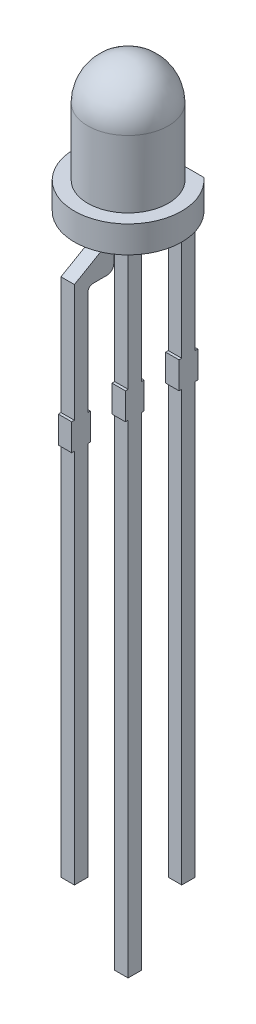
from build123d import *

# Parameters (mm, degrees)
EXTRUDE1_DEPTH     = 1
EXTRUDE2_DEPTH     = 0.25
SKETCH3_W          = 0.026582278
SKETCH3_H          = 0.025316456
CUT_EXTRUDE1_DEPTH = 0.01


with BuildPart() as part:
    # Sketch1 → Extrude1 (new body)
    with BuildSketch(Plane(origin=(0, 0, 0), x_dir=(1, 0, 0), z_dir=(0, 1, 0))):
        with BuildLine():
            Line((1.322875656, 1.5), (-1.322875656, 1.5))
            ThreePointArc((-1.322875656, 1.5), (-0.822875656, -1.822875656), (2, 0))
            ThreePointArc((2, 0), (1.822875656, 0.822875656), (1.322875656, 1.5))
        make_face()
    extrude(amount=EXTRUDE1_DEPTH)

    # Sketch2 → Revolve1 (revolve)
    with BuildSketch(Plane(origin=(0, 0, 0), x_dir=(0, 0, -1), z_dir=(1, 0, 0)), mode=Mode.PRIVATE) as revolve1_sk:
        with BuildLine():
            ThreePointArc((0, 5), (1.060660172, 4.560660172), (1.5, 3.5))
            Line((1.5, 3.5), (1.5, 1))
            Line((1.5, 1), (0, 1))
            Line((0, 1), (0, 5))
        make_face()
    revolve(revolve1_sk.sketch.rotate(Axis((0, 1, 0), (0, 1, 0)), 180), axis=Axis((0, 1, 0), (0, 1, 0)))  # turned: the seam where the file's is

    # Sketch2_3 → Extrude2 (add, symmetric)
    with BuildSketch(Plane(origin=(0, 0, 0), x_dir=(0, 0, -1), z_dir=(1, 0, 0))):
        with BuildLine():
            Line((1.177495486, -0.5), (1.177495486, 0))
            Line((1.177495486, 0), (0.677495486, 0))
            Line((0.677495486, 0), (0.677495486, -1.03))
            ThreePointArc((0.677495486, -1.03), (0.794652774, -1.312842712), (1.077495486, -1.43))
            Line((1.077495486, -1.43), (1.65, -1.43))
            ThreePointArc((1.65, -1.43), (1.720710678, -1.459289322), (1.75, -1.53))
            Line((1.75, -1.53), (1.75, -5.5))
            Line((1.75, -5.5), (1.65, -5.5))
            Line((1.65, -5.5), (1.65, -6.5))
            Line((1.65, -6.5), (1.75, -6.5))
            Line((1.75, -6.5), (1.75, -22.5))
            Line((1.75, -22.5), (2.25, -22.5))
            Line((2.25, -22.5), (2.25, -6.5))
            Line((2.25, -6.5), (2.35, -6.5))
            Line((2.35, -6.5), (2.35, -5.5))
            Line((2.35, -5.5), (2.25, -5.5))
            Line((2.25, -5.5), (2.25, -1.11921077))
            Line((2.25, -1.11921077), (1.177495486, -0.5))
        make_face()
        with BuildLine():
            Line((-0.677495486, 0), (-1.177495486, 0))
            Line((-1.177495486, 0), (-1.177495486, -0.5))
            Line((-1.177495486, -0.5), (-2.25, -1.11921077))
            Line((-2.25, -1.11921077), (-2.25, -5.5))
            Line((-2.25, -5.5), (-2.35, -5.5))
            Line((-2.35, -5.5), (-2.35, -6.5))
            Line((-2.35, -6.5), (-2.25, -6.5))
            Line((-2.25, -6.5), (-2.25, -20.5))
            Line((-2.25, -20.5), (-1.75, -20.5))
            Line((-1.75, -20.5), (-1.75, -6.5))
            Line((-1.75, -6.5), (-1.65, -6.5))
            Line((-1.65, -6.5), (-1.65, -5.5))
            Line((-1.65, -5.5), (-1.75, -5.5))
            Line((-1.75, -5.5), (-1.75, -1.63))
            ThreePointArc((-1.75, -1.63), (-1.691421356, -1.488578644), (-1.55, -1.43))
            Line((-1.55, -1.43), (-1.03296796, -1.43))
            ThreePointArc((-1.03296796, -1.43), (-0.856191265, -1.356776695), (-0.78296796, -1.18))
            Line((-0.78296796, -1.18), (-0.78296796, -0.913641717))
            Line((-0.78296796, -0.913641717), (-0.677495486, -0.858841506))
            Line((-0.677495486, -0.858841506), (-0.677495486, 0))
        make_face()
        Polygon((0.25, 0), (-0.25, 0), (-0.25, -5.5), (-0.35, -5.5), (-0.35, -6.5), (-0.25, -6.5), (-0.25, -24.5), (0.25, -24.5), (0.25, -6.5), (0.35, -6.5), (0.35, -5.5), (0.25, -5.5), align=None)
    extrude(amount=EXTRUDE2_DEPTH, both=True)

    # Sketch3 → Cut-Extrude1 (cut)
    with BuildSketch(Plane.XZ):
        Polygon((-0.623396943, 0.759259634), (-0.698080487, 0.782716913), (-0.698080487, 0.807459793), (-0.647744253, 0.823875932), (-0.698080487, 0.83940204), (-0.698080487, 0.865133843), (-0.623396943, 0.888373558), (-0.623396943, 0.863195552), (-0.674880329, 0.85020109), (-0.623396943, 0.833784951), (-0.623396943, 0.812285742), (-0.674880329, 0.795968495), (-0.623396943, 0.78315204), align=None)
        Polygon((-0.623396943, 0.625082419), (-0.698080487, 0.648539698), (-0.698080487, 0.673282577), (-0.647744253, 0.689698717), (-0.698080487, 0.705224824), (-0.698080487, 0.730956628), (-0.623396943, 0.754196343), (-0.623396943, 0.729018337), (-0.674880329, 0.716023875), (-0.623396943, 0.699607736), (-0.623396943, 0.678108527), (-0.674880329, 0.66179128), (-0.623396943, 0.648974824), align=None)
        Polygon((-0.623396943, 0.490905204), (-0.698080487, 0.514362483), (-0.698080487, 0.539105362), (-0.647744253, 0.555521502), (-0.698080487, 0.571047609), (-0.698080487, 0.596779413), (-0.623396943, 0.620019128), (-0.623396943, 0.594841122), (-0.674880329, 0.58184666), (-0.623396943, 0.565430521), (-0.623396943, 0.543931312), (-0.674880329, 0.527614065), (-0.623396943, 0.514797609), align=None)
        with Locations((-0.684789348, 0.463057103)):
            Rectangle(SKETCH3_W, SKETCH3_H)
        with BuildLine():
            add(Edge.make_bspline(
                [(-0.666909601, 0.346601407), (-0.668131735, 0.346637905), (-0.670531598, 0.346709575), (-0.674039286, 0.347319162), (-0.677363589, 0.348313129), (-0.680527735, 0.349685468), (-0.683497223, 0.351478924), (-0.686300115, 0.353662195), (-0.688904659, 0.356251078), (-0.691341034, 0.359197882), (-0.693523145, 0.362494825), (-0.695429179, 0.366092539), (-0.69702385, 0.369972566), (-0.698362915, 0.374120777), (-0.699351348, 0.378567324), (-0.700075336, 0.383284822), (-0.700548654, 0.38827825), (-0.700590622, 0.391701827), (-0.700612133, 0.393456628)],
                knots=[0, 0, 0, 0, 0.907312236, 1.78165839, 2.635367075, 3.479697475, 4.336364812, 5.205276731, 6.11257575, 7.058770404, 8.040786331, 9.044147278, 10.078219212, 11.153049307, 12.278104542, 13.457648573, 14.696882856, 16, 16, 16, 16], degree=3))
            add(Edge.make_bspline(
                [(-0.700612133, 0.393456628), (-0.700588061, 0.395474884), (-0.700541437, 0.399384066), (-0.700112837, 0.405047591), (-0.699466698, 0.410315628), (-0.698500156, 0.415211343), (-0.697299391, 0.419815942), (-0.696008099, 0.42424921), (-0.694543684, 0.428530522), (-0.693443526, 0.431303611), (-0.692898525, 0.432677356)],
                knots=[0, 0, 0, 0, 1.203215828, 2.33052265, 3.384689099, 4.366106119, 5.303329643, 6.221311756, 7.118865988, 8, 8, 8, 8], degree=3))
            Line((-0.692898525, 0.432677356), (-0.668966563, 0.432677356))
            Line((-0.668966563, 0.432677356), (-0.668966563, 0.429829255))
            add(Edge.make_bspline(
                [(-0.668966563, 0.429829255), (-0.670048018, 0.428463941), (-0.672204579, 0.425741328), (-0.674967184, 0.421308095), (-0.677369347, 0.416660449), (-0.679343349, 0.411814978), (-0.680929673, 0.406918134), (-0.682023201, 0.402042756), (-0.68277055, 0.397277169), (-0.682851056, 0.394118599), (-0.682890614, 0.392566596)],
                knots=[0, 0, 0, 0, 1.030622468, 2.055194264, 3.087043286, 4.125157485, 5.149848264, 6.130935704, 7.081611712, 8, 8, 8, 8], degree=3))
            add(Edge.make_bspline(
                [(-0.682890614, 0.392566596), (-0.682889719, 0.392137818), (-0.682887805, 0.391219836), (-0.682758962, 0.389751799), (-0.682665798, 0.3880932), (-0.68245658, 0.386314334), (-0.682237997, 0.384523516), (-0.681857677, 0.382868856), (-0.681495838, 0.381365217), (-0.681127661, 0.380458735), (-0.680952323, 0.38002704)],
                knots=[0, 0, 0, 0, 0.806378557, 1.726393851, 2.771014456, 3.931269413, 5.096090628, 6.161710732, 7.124547685, 8, 8, 8, 8], degree=3))
            add(Edge.make_bspline(
                [(-0.680952323, 0.38002704), (-0.680724499, 0.379547253), (-0.680276777, 0.378604369), (-0.67945917, 0.37730945), (-0.678587868, 0.376126778), (-0.677622449, 0.375065317), (-0.676444541, 0.37421505), (-0.675043685, 0.373586849), (-0.673393384, 0.373243755), (-0.672218374, 0.373204461), (-0.671597101, 0.373183685)],
                knots=[0, 0, 0, 0, 1.024407818, 2.013179384, 2.949802342, 3.859052226, 4.77034807, 5.732977883, 6.801339628, 8, 8, 8, 8], degree=3))
            add(Edge.make_bspline(
                [(-0.671597101, 0.373183685), (-0.671051205, 0.373215127), (-0.669977813, 0.37327695), (-0.668449816, 0.373858742), (-0.667027939, 0.37474164), (-0.665767224, 0.376028663), (-0.664609786, 0.377622739), (-0.663639489, 0.379578476), (-0.662759415, 0.381831455), (-0.662342146, 0.383475914), (-0.662123209, 0.384338748)],
                knots=[0, 0, 0, 0, 0.825212765, 1.622611382, 2.449701629, 3.348069183, 4.336544339, 5.428209675, 6.6506027, 8, 8, 8, 8], degree=3))
            add(Edge.make_bspline(
                [(-0.662123209, 0.384338748), (-0.661675468, 0.386307476), (-0.660758278, 0.390340383), (-0.659611171, 0.396488492), (-0.658345098, 0.40261872), (-0.657135557, 0.406577432), (-0.656545677, 0.408508052)],
                knots=[0, 0, 0, 0, 0.976104583, 1.999535498, 3.024395274, 4, 4, 4, 4], degree=3))
            add(Edge.make_bspline(
                [(-0.656545677, 0.408508052), (-0.656192685, 0.409546568), (-0.655505551, 0.411568136), (-0.654343926, 0.41445968), (-0.653073974, 0.417120793), (-0.651718843, 0.419560903), (-0.650244845, 0.421760225), (-0.648711456, 0.423755415), (-0.647057618, 0.425498941), (-0.645325699, 0.427046625), (-0.643473696, 0.428369939), (-0.64152956, 0.42952469), (-0.639469094, 0.430500325), (-0.637307806, 0.431309209), (-0.635028937, 0.431926281), (-0.632652064, 0.432347537), (-0.630168703, 0.432645926), (-0.62847435, 0.432666737), (-0.627609759, 0.432677356)],
                knots=[0, 0, 0, 0, 1.287286806, 2.505824366, 3.654938963, 4.74627059, 5.778586806, 6.75996495, 7.696030012, 8.595059759, 9.482019644, 10.363222407, 11.245851011, 12.154256429, 13.068444161, 14.012503255, 14.985824751, 16, 16, 16, 16], degree=3))
            add(Edge.make_bspline(
                [(-0.627609759, 0.432677356), (-0.626453615, 0.432640054), (-0.624178343, 0.432566645), (-0.620849298, 0.431965216), (-0.617700562, 0.430938626), (-0.614697099, 0.429552562), (-0.611884012, 0.427723934), (-0.609205465, 0.42553914), (-0.606733874, 0.422915092), (-0.60443354, 0.419937971), (-0.602354141, 0.416650587), (-0.600523585, 0.413111603), (-0.598986933, 0.409342314), (-0.597713039, 0.405356767), (-0.596758369, 0.401138298), (-0.596039437, 0.396701066), (-0.595626255, 0.392027277), (-0.595575005, 0.388835855), (-0.595548842, 0.387206628)],
                knots=[0, 0, 0, 0, 0.894990994, 1.761326291, 2.609044902, 3.454222546, 4.315366365, 5.200560057, 6.125081389, 7.100429509, 8.110379559, 9.133447974, 10.182136699, 11.259192205, 12.370181258, 13.528580438, 14.738335141, 16, 16, 16, 16], degree=3))
            add(Edge.make_bspline(
                [(-0.595548842, 0.387206628), (-0.595571033, 0.385537941), (-0.595615379, 0.382203396), (-0.595993356, 0.377221954), (-0.596548584, 0.372261452), (-0.59739029, 0.367397622), (-0.598366707, 0.362707067), (-0.599462503, 0.358293831), (-0.600700467, 0.35421437), (-0.601654812, 0.351640706), (-0.602115297, 0.350398875)],
                knots=[0, 0, 0, 0, 1.065403572, 2.129000689, 3.188532477, 4.251604565, 5.279552602, 6.247508681, 7.154397237, 8, 8, 8, 8], degree=3))
            Line((-0.602115297, 0.350398875), (-0.624662766, 0.350398875))
            Line((-0.624662766, 0.350398875), (-0.624662766, 0.353227198))
            add(Edge.make_bspline(
                [(-0.624662766, 0.353227198), (-0.623862419, 0.354300102), (-0.622225689, 0.356494221), (-0.620142017, 0.360153858), (-0.618184151, 0.364112093), (-0.616499993, 0.368390924), (-0.615040511, 0.372849951), (-0.614021345, 0.37743291), (-0.613379536, 0.382059074), (-0.613306761, 0.385160785), (-0.613270361, 0.386712166)],
                knots=[0, 0, 0, 0, 0.892283326, 1.824742884, 2.804416662, 3.836872171, 4.8899239, 5.931447339, 6.965372909, 8, 8, 8, 8], degree=3))
            add(Edge.make_bspline(
                [(-0.613270361, 0.386712166), (-0.613291813, 0.387807834), (-0.613334715, 0.38999905), (-0.613725399, 0.393267259), (-0.614356293, 0.39650932), (-0.615175575, 0.398549843), (-0.615584443, 0.399568179)],
                knots=[0, 0, 0, 0, 0.999146175, 1.998183711, 3.000980573, 4, 4, 4, 4], degree=3))
            add(Edge.make_bspline(
                [(-0.615584443, 0.399568179), (-0.61578591, 0.400001682), (-0.616188709, 0.400868399), (-0.616961273, 0.402075044), (-0.617890084, 0.403179713), (-0.618942076, 0.40417179), (-0.62009845, 0.405040188), (-0.621373276, 0.405655539), (-0.62273619, 0.406031412), (-0.623671421, 0.406073571), (-0.624148525, 0.406095077)],
                knots=[0, 0, 0, 0, 1.00524851, 2.009826503, 3.004679593, 4.035271301, 5.048246368, 6.034938417, 6.997532266, 8, 8, 8, 8], degree=3))
            add(Edge.make_bspline(
                [(-0.624148525, 0.406095077), (-0.624786691, 0.406060639), (-0.626006166, 0.405994831), (-0.627721962, 0.405388247), (-0.629200396, 0.404403413), (-0.630195316, 0.403242809), (-0.630892754, 0.402125679), (-0.631403265, 0.401090019), (-0.631886624, 0.399880792), (-0.632384092, 0.398509545), (-0.632875279, 0.396973218), (-0.633350826, 0.395264661), (-0.633800122, 0.393381944), (-0.634086313, 0.392066069), (-0.634235551, 0.391379888)],
                knots=[0, 0, 0, 0, 1.173816843, 2.243057204, 3.312297565, 4.415174738, 5.03266065, 5.73970059, 6.541434878, 7.433956553, 8.430083051, 9.515931566, 10.70464786, 12, 12, 12, 12], degree=3))
            add(Edge.make_bspline(
                [(-0.634235551, 0.391379888), (-0.634611612, 0.389547098), (-0.63535049, 0.385946072), (-0.636453978, 0.380544889), (-0.637728947, 0.375042115), (-0.63887775, 0.371376789), (-0.639476848, 0.369465331)],
                knots=[0, 0, 0, 0, 0.995744513, 1.956417928, 2.934277412, 4, 4, 4, 4], degree=3))
            add(Edge.make_bspline(
                [(-0.639476848, 0.369465331), (-0.639796092, 0.368518776), (-0.640420585, 0.366667163), (-0.641506867, 0.364026533), (-0.64268085, 0.361579474), (-0.643922382, 0.359312441), (-0.645266348, 0.357238471), (-0.646688994, 0.355343789), (-0.648215903, 0.353659971), (-0.649829131, 0.352162405), (-0.651539232, 0.350843246), (-0.653378304, 0.349710947), (-0.655327106, 0.348738719), (-0.657413306, 0.347969114), (-0.659607893, 0.347351094), (-0.661939261, 0.346927997), (-0.664383638, 0.346634013), (-0.666058215, 0.346612397), (-0.666909601, 0.346601407)],
                knots=[0, 0, 0, 0, 1.237467875, 2.420686895, 3.535046182, 4.599015201, 5.620884487, 6.594603852, 7.531477383, 8.433220087, 9.318759595, 10.202828513, 11.105163009, 12.01247538, 12.953896178, 13.926381251, 14.945733412, 16, 16, 16, 16], degree=3))
        make_face()
        with BuildLine():
            Line((-0.698080487, 0.254196343), (-0.698080487, 0.278246976))
            Line((-0.698080487, 0.278246976), (-0.690248209, 0.278246976))
            add(Edge.make_bspline(
                [(-0.690248209, 0.278246976), (-0.691056767, 0.279340285), (-0.692615656, 0.281448168), (-0.694695873, 0.284621193), (-0.696471139, 0.287647284), (-0.69803036, 0.290560774), (-0.699205746, 0.293582978), (-0.700033812, 0.296814492), (-0.700533584, 0.300317317), (-0.700585368, 0.302744211), (-0.700612133, 0.303998558)],
                knots=[0, 0, 0, 0, 1.150872466, 2.218865267, 3.209461834, 4.120482262, 5.012764827, 5.946708227, 6.938749913, 8, 8, 8, 8], degree=3))
            add(Edge.make_bspline(
                [(-0.700612133, 0.303998558), (-0.700589414, 0.30501491), (-0.700545174, 0.306994041), (-0.700200296, 0.309871281), (-0.699662644, 0.312578909), (-0.698855053, 0.315093949), (-0.69788925, 0.317457938), (-0.696609292, 0.319595488), (-0.695179118, 0.321599089), (-0.693472072, 0.323380762), (-0.691574339, 0.324996383), (-0.689441879, 0.326378933), (-0.687108954, 0.327556644), (-0.6845571, 0.328497742), (-0.681798796, 0.329252832), (-0.678819549, 0.329776764), (-0.675632421, 0.330097356), (-0.673437291, 0.330129296), (-0.672309127, 0.33014571)],
                knots=[0, 0, 0, 0, 1.109008058, 2.159558935, 3.158726032, 4.116861086, 5.039058877, 5.938775559, 6.82970133, 7.720510853, 8.624361809, 9.544451588, 10.487360536, 11.471068125, 12.508000841, 13.604731202, 14.768976642, 16, 16, 16, 16], degree=3))
            Line((-0.672309127, 0.33014571), (-0.623396943, 0.33014571))
            Line((-0.623396943, 0.33014571), (-0.623396943, 0.306095077))
            Line((-0.623396943, 0.306095077), (-0.660976057, 0.306095077))
            add(Edge.make_bspline(
                [(-0.660976057, 0.306095077), (-0.661892528, 0.306093442), (-0.663646744, 0.306090311), (-0.66615255, 0.306007973), (-0.668420723, 0.305887072), (-0.670462751, 0.305748367), (-0.672309502, 0.305495351), (-0.673975663, 0.305117642), (-0.675495265, 0.304646816), (-0.676401966, 0.304182497), (-0.676838399, 0.303959002)],
                knots=[0, 0, 0, 0, 1.361401701, 2.605856924, 3.723918663, 4.735739235, 5.645738665, 6.489217889, 7.27279937, 8, 8, 8, 8], degree=3))
            add(Edge.make_bspline(
                [(-0.676838399, 0.303959002), (-0.677237114, 0.303728995), (-0.678020953, 0.303276821), (-0.679027131, 0.302356532), (-0.679871399, 0.301277789), (-0.680527427, 0.300000185), (-0.681026376, 0.298513637), (-0.681366613, 0.296785706), (-0.681582114, 0.294800345), (-0.681610023, 0.293391327), (-0.681624791, 0.29264571)],
                knots=[0, 0, 0, 0, 0.849138082, 1.669332372, 2.503455908, 3.370611167, 4.311442699, 5.394692208, 6.621337967, 8, 8, 8, 8], degree=3))
            add(Edge.make_bspline(
                [(-0.681624791, 0.29264571), (-0.681607434, 0.292104426), (-0.681571747, 0.290991509), (-0.681339301, 0.289280196), (-0.680982626, 0.287483619), (-0.680322771, 0.284969037), (-0.679136591, 0.281802409), (-0.677782184, 0.279443108), (-0.677095519, 0.278246976)],
                knots=[0, 0, 0, 0, 0.638127216, 1.312033637, 2.033062677, 2.79661882, 4.375931797, 6, 6, 6, 6], degree=3))
            Line((-0.677095519, 0.278246976), (-0.623396943, 0.278246976))
            Line((-0.623396943, 0.278246976), (-0.623396943, 0.254196343))
            Line((-0.623396943, 0.254196343), (-0.698080487, 0.254196343))
        make_face()
        with BuildLine():
            Line((-0.698080487, 0.156727989), (-0.698080487, 0.180778622))
            Line((-0.698080487, 0.180778622), (-0.660501373, 0.180778622))
            add(Edge.make_bspline(
                [(-0.660501373, 0.180778622), (-0.658971331, 0.180803136), (-0.655920305, 0.18085202), (-0.652157895, 0.181134144), (-0.64931557, 0.181512666), (-0.647477689, 0.181882321), (-0.64592955, 0.182314021), (-0.645043791, 0.182726301), (-0.644639032, 0.182914698)],
                knots=[0, 0, 0, 0, 1.709124929, 3.408128882, 4.211124727, 4.91016634, 5.501986363, 6, 6, 6, 6], degree=3))
            add(Edge.make_bspline(
                [(-0.644639032, 0.182914698), (-0.644240978, 0.18315916), (-0.643460539, 0.183638464), (-0.642447525, 0.184575788), (-0.641618684, 0.185669674), (-0.640937134, 0.186940444), (-0.640466553, 0.188431641), (-0.640073323, 0.190148381), (-0.639906414, 0.192134999), (-0.639871254, 0.193542269), (-0.639852639, 0.194287324)],
                knots=[0, 0, 0, 0, 0.86006424, 1.686277094, 2.52783008, 3.38194165, 4.331801563, 5.402842185, 6.624978739, 8, 8, 8, 8], degree=3))
            add(Edge.make_bspline(
                [(-0.639852639, 0.194287324), (-0.639909377, 0.195419146), (-0.64002523, 0.197730241), (-0.640736737, 0.200592434), (-0.641555697, 0.202923038), (-0.642314527, 0.204775562), (-0.643285969, 0.206684193), (-0.644007791, 0.207963605), (-0.644381911, 0.208626723)],
                knots=[0, 0, 0, 0, 1.338371478, 2.732853438, 3.468019217, 4.261884641, 5.099136535, 6, 6, 6, 6], degree=3))
            Line((-0.644381911, 0.208626723), (-0.698080487, 0.208626723))
            Line((-0.698080487, 0.208626723), (-0.698080487, 0.232677356))
            Line((-0.698080487, 0.232677356), (-0.623396943, 0.232677356))
            Line((-0.623396943, 0.232677356), (-0.623396943, 0.208626723))
            Line((-0.623396943, 0.208626723), (-0.631229221, 0.208626723))
            add(Edge.make_bspline(
                [(-0.631229221, 0.208626723), (-0.63042307, 0.207569316), (-0.628853848, 0.205511012), (-0.626813427, 0.202331774), (-0.625014658, 0.199247876), (-0.623501841, 0.196194866), (-0.622295067, 0.193079911), (-0.621484078, 0.189817153), (-0.620940275, 0.186400747), (-0.620890581, 0.184064032), (-0.620865297, 0.182875141)],
                knots=[0, 0, 0, 0, 1.126119141, 2.192057864, 3.198061997, 4.149848529, 5.076251285, 6.021887753, 6.99356175, 8, 8, 8, 8], degree=3))
            add(Edge.make_bspline(
                [(-0.620865297, 0.182875141), (-0.620890686, 0.181878869), (-0.62094025, 0.17993397), (-0.62124996, 0.17709921), (-0.621800624, 0.174427789), (-0.622598454, 0.171935515), (-0.623584066, 0.169592895), (-0.624815581, 0.167430951), (-0.626274004, 0.16543888), (-0.627935006, 0.163610479), (-0.629824733, 0.161979661), (-0.631941997, 0.160562625), (-0.634285094, 0.159382643), (-0.636845403, 0.158411931), (-0.639610512, 0.157637508), (-0.642606477, 0.157122377), (-0.645810656, 0.156768593), (-0.648026699, 0.156741794), (-0.649168304, 0.156727989)],
                knots=[0, 0, 0, 0, 1.08848837, 2.124922927, 3.110950502, 4.063144162, 4.979605775, 5.882838355, 6.774625441, 7.671951181, 8.57587277, 9.494821853, 10.448322275, 11.435533005, 12.482327682, 13.580118324, 14.753386918, 16, 16, 16, 16], degree=3))
            Line((-0.649168304, 0.156727989), (-0.698080487, 0.156727989))
        make_face()
        Polygon((-0.698080487, 0.06179128), (-0.698080487, 0.133943179), (-0.598080487, 0.133943179), (-0.598080487, 0.108626723), (-0.679093146, 0.108626723), (-0.679093146, 0.06179128), align=None)
        Polygon((-0.698080487, -0.025550492), (-0.698080487, 0.046601407), (-0.598080487, 0.046601407), (-0.598080487, -0.025550492), (-0.617067829, -0.025550492), (-0.617067829, 0.021284951), (-0.634789348, 0.021284951), (-0.634789348, -0.021753024), (-0.65377669, -0.021753024), (-0.65377669, 0.021284951), (-0.679093146, 0.021284951), (-0.679093146, -0.025550492), align=None)
        with BuildLine():
            add(Edge.make_bspline(
                [(-0.64817938, -0.142006188), (-0.649327069, -0.141986873), (-0.651599955, -0.141948621), (-0.654964761, -0.14165343), (-0.658230437, -0.141127404), (-0.661414685, -0.140448223), (-0.664493613, -0.139525717), (-0.66750119, -0.138444003), (-0.670406684, -0.137134357), (-0.673208118, -0.135629505), (-0.675880221, -0.133980033), (-0.67840043, -0.132205284), (-0.680783648, -0.130359504), (-0.682978541, -0.128370192), (-0.685020561, -0.12629101), (-0.686911375, -0.124115482), (-0.688614806, -0.121810417), (-0.68963769, -0.120203255), (-0.690149316, -0.119399385)],
                knots=[0, 0, 0, 0, 1.105570398, 2.18947457, 3.250358341, 4.290584537, 5.323553275, 6.344225964, 7.367641686, 8.3905646, 9.405808457, 10.390761353, 11.358902336, 12.307789878, 13.241960776, 14.165076779, 15.082208636, 16, 16, 16, 16], degree=3))
            add(Edge.make_bspline(
                [(-0.690149316, -0.119399385), (-0.690861456, -0.118160156), (-0.692289368, -0.115675377), (-0.693957959, -0.111691542), (-0.695362075, -0.10756606), (-0.696416499, -0.103215673), (-0.697143543, -0.098568664), (-0.69770435, -0.093567255), (-0.69800611, -0.088159665), (-0.69805513, -0.08442477), (-0.698080487, -0.082492739)],
                knots=[0, 0, 0, 0, 0.896288622, 1.797150563, 2.705281913, 3.629615989, 4.602417572, 5.655716007, 6.787320449, 8, 8, 8, 8], degree=3))
            Line((-0.698080487, -0.082492739), (-0.698080487, -0.047069479))
            Line((-0.698080487, -0.047069479), (-0.598080487, -0.047069479))
            Line((-0.598080487, -0.047069479), (-0.598080487, -0.083501442))
            add(Edge.make_bspline(
                [(-0.598080487, -0.083501442), (-0.598097098, -0.085480173), (-0.598129139, -0.089296902), (-0.598546729, -0.094813741), (-0.599143554, -0.099918949), (-0.600068424, -0.104604297), (-0.60118377, -0.108904301), (-0.602542898, -0.112829777), (-0.604041605, -0.116441551), (-0.605315299, -0.118620393), (-0.605932544, -0.119676283)],
                knots=[0, 0, 0, 0, 1.267175336, 2.444223962, 3.542125549, 4.557526608, 5.500936977, 6.385043188, 7.217374394, 8, 8, 8, 8], degree=3))
            add(Edge.make_bspline(
                [(-0.605932544, -0.119676283), (-0.606469085, -0.120527237), (-0.607535998, -0.122219361), (-0.609317851, -0.124620576), (-0.611273928, -0.126850003), (-0.613325746, -0.128978506), (-0.615528633, -0.130958324), (-0.61786734, -0.132801523), (-0.620345434, -0.13450534), (-0.622954904, -0.136063304), (-0.625684955, -0.137484119), (-0.628558014, -0.138673425), (-0.631536544, -0.139722774), (-0.634645507, -0.14052831), (-0.637853343, -0.141226224), (-0.641194687, -0.141660959), (-0.644647175, -0.14194757), (-0.646992065, -0.141986484), (-0.64817938, -0.142006188)],
                knots=[0, 0, 0, 0, 0.964065863, 1.917049184, 2.86229036, 3.805247319, 4.749389377, 5.698846072, 6.657678277, 7.629829384, 8.610569287, 9.604676042, 10.607940105, 11.6349849, 12.681042988, 13.752616828, 14.862056989, 16, 16, 16, 16], degree=3))
        make_face()
        with BuildLine():
            add(Edge.make_bspline(
                [(-0.648021152, -0.11542391), (-0.647216392, -0.115413669), (-0.645637808, -0.115393582), (-0.643322293, -0.115202014), (-0.641092643, -0.114942958), (-0.638957951, -0.114511904), (-0.636898381, -0.114012257), (-0.634940886, -0.113370108), (-0.633061313, -0.112645711), (-0.631283825, -0.111764073), (-0.629575442, -0.110790436), (-0.627989927, -0.109642943), (-0.626477041, -0.108394605), (-0.625049056, -0.107016318), (-0.62374316, -0.105473378), (-0.622513084, -0.103813276), (-0.621384758, -0.102012918), (-0.620724708, -0.10073993), (-0.620390614, -0.100095587)],
                knots=[0, 0, 0, 0, 1.152093354, 2.259898929, 3.325467225, 4.364140538, 5.376172865, 6.358396836, 7.312077728, 8.257828931, 9.196960457, 10.124297759, 11.056236784, 12.004246951, 12.961658638, 13.947279359, 14.960983522, 16, 16, 16, 16], degree=3))
            add(Edge.make_bspline(
                [(-0.620390614, -0.100095587), (-0.620083902, -0.099420689), (-0.619475977, -0.098082995), (-0.618744785, -0.096012172), (-0.618171949, -0.093922789), (-0.617741091, -0.091721189), (-0.61741916, -0.08925143), (-0.617221902, -0.086325848), (-0.617079732, -0.082869939), (-0.617071981, -0.080383224), (-0.617067829, -0.079051283)],
                knots=[0, 0, 0, 0, 0.826967603, 1.639107464, 2.447640171, 3.242670507, 4.14065217, 5.225198036, 6.513753944, 8, 8, 8, 8], degree=3))
            Line((-0.617067829, -0.079051283), (-0.617067829, -0.072385935))
            Line((-0.617067829, -0.072385935), (-0.679093146, -0.072385935))
            Line((-0.679093146, -0.072385935), (-0.679093146, -0.079051283))
            add(Edge.make_bspline(
                [(-0.679093146, -0.079051283), (-0.679088396, -0.07980949), (-0.679079226, -0.081273256), (-0.679036164, -0.083389499), (-0.678989277, -0.085355295), (-0.678872814, -0.087160166), (-0.678800168, -0.088818851), (-0.678621789, -0.090305632), (-0.67847961, -0.091648122), (-0.678211887, -0.093215718), (-0.677795704, -0.095068884), (-0.677117525, -0.097230144), (-0.676267129, -0.099370679), (-0.675582162, -0.100759252), (-0.675236342, -0.101460302)],
                knots=[0, 0, 0, 0, 1.186793418, 2.291178421, 3.313283093, 4.264083014, 5.122158624, 5.910777728, 6.607099052, 7.234812932, 8.398911528, 9.577194775, 10.776795607, 12, 12, 12, 12], degree=3))
            add(Edge.make_bspline(
                [(-0.675236342, -0.101460302), (-0.674894826, -0.102045418), (-0.674221311, -0.103199344), (-0.673087237, -0.104822849), (-0.671879513, -0.106330566), (-0.670591061, -0.107726578), (-0.66920282, -0.108989878), (-0.667736278, -0.110141897), (-0.6661883, -0.111172346), (-0.663994782, -0.112407735), (-0.660963846, -0.113630981), (-0.656996459, -0.114670523), (-0.652636696, -0.115307395), (-0.649599078, -0.115384077), (-0.648021152, -0.11542391)],
                knots=[0, 0, 0, 0, 0.755160452, 1.489275589, 2.205657296, 2.907868421, 3.605098304, 4.296256403, 4.985378686, 5.676536785, 7.100390329, 8.614249252, 10.241231541, 12, 12, 12, 12], degree=3))
        make_face(mode=Mode.SUBTRACT)
        with Locations((-0.684789348, -0.173651758)):
            Rectangle(SKETCH3_W, SKETCH3_H)
        with BuildLine():
            add(Edge.make_bspline(
                [(-0.700612133, -0.248295745), (-0.700590322, -0.246705632), (-0.70054751, -0.243584496), (-0.700070593, -0.239013154), (-0.699352898, -0.234647982), (-0.698331991, -0.230501674), (-0.696984495, -0.226587882), (-0.695331559, -0.222924245), (-0.693346375, -0.219517388), (-0.691767166, -0.217458741), (-0.690980013, -0.216432612)],
                knots=[0, 0, 0, 0, 1.123670284, 2.205584497, 3.245308791, 4.249063313, 5.220352711, 6.167273909, 7.086481357, 8, 8, 8, 8], degree=3))
            add(Edge.make_bspline(
                [(-0.690980013, -0.216432612), (-0.690125238, -0.215480865), (-0.688418996, -0.21358105), (-0.685447569, -0.211115117), (-0.682164525, -0.208992032), (-0.678562302, -0.207206479), (-0.674645573, -0.205775555), (-0.670400911, -0.204752422), (-0.665840131, -0.204133176), (-0.662692197, -0.204066011), (-0.661074949, -0.204031505)],
                knots=[0, 0, 0, 0, 0.916457077, 1.82937027, 2.759194969, 3.714948755, 4.706655623, 5.743329475, 6.840637961, 8, 8, 8, 8], degree=3))
            add(Edge.make_bspline(
                [(-0.661074949, -0.204031505), (-0.659371722, -0.204070265), (-0.656070642, -0.204145388), (-0.651298455, -0.204809148), (-0.646880774, -0.20587876), (-0.642828866, -0.207416318), (-0.639135674, -0.20934676), (-0.635763839, -0.211611253), (-0.632720915, -0.214231779), (-0.630975476, -0.216238917), (-0.630101848, -0.21724353)],
                knots=[0, 0, 0, 0, 1.171797512, 2.271099083, 3.308930235, 4.294129479, 5.24602549, 6.17106565, 7.084581485, 8, 8, 8, 8], degree=3))
            add(Edge.make_bspline(
                [(-0.630101848, -0.21724353), (-0.629333262, -0.2182694), (-0.627786806, -0.220333532), (-0.625886106, -0.223737037), (-0.62429132, -0.227360252), (-0.623043676, -0.231189823), (-0.62208977, -0.235162632), (-0.621365927, -0.239222291), (-0.620945368, -0.243368544), (-0.620892116, -0.246158744), (-0.620865297, -0.247563942)],
                knots=[0, 0, 0, 0, 0.952130878, 1.915761808, 2.890227217, 3.891541892, 4.905612075, 5.925811839, 6.955400088, 8, 8, 8, 8], degree=3))
            add(Edge.make_bspline(
                [(-0.620865297, -0.247563942), (-0.6208823, -0.24881066), (-0.620915732, -0.251262132), (-0.621237841, -0.254863178), (-0.62177096, -0.25831772), (-0.622509563, -0.261622652), (-0.623401166, -0.264796598), (-0.624440308, -0.267846775), (-0.625573575, -0.270806585), (-0.62645811, -0.272707154), (-0.626897734, -0.273651758)],
                knots=[0, 0, 0, 0, 1.107648782, 2.178012834, 3.209595929, 4.211695017, 5.185427128, 6.137685403, 7.07440854, 8, 8, 8, 8], degree=3))
            Line((-0.626897734, -0.273651758), (-0.647447576, -0.273651758))
            Line((-0.647447576, -0.273651758), (-0.647447576, -0.270309195))
            add(Edge.make_bspline(
                [(-0.647447576, -0.270309195), (-0.647030356, -0.269809651), (-0.646128642, -0.268730015), (-0.644707889, -0.266943599), (-0.643178296, -0.264794657), (-0.64228635, -0.263141121), (-0.641810709, -0.262259353)],
                knots=[0, 0, 0, 0, 0.792826818, 1.713491785, 2.780691913, 4, 4, 4, 4], degree=3))
            add(Edge.make_bspline(
                [(-0.641810709, -0.262259353), (-0.641368751, -0.261331418), (-0.640462891, -0.259429473), (-0.639630057, -0.256873468), (-0.639062331, -0.254681466), (-0.638805909, -0.25286393), (-0.638616348, -0.25093031), (-0.638596841, -0.249595068), (-0.638586816, -0.248908878)],
                knots=[0, 0, 0, 0, 1.332524827, 2.731214173, 3.480270227, 4.267952375, 5.109889624, 6, 6, 6, 6], degree=3))
            add(Edge.make_bspline(
                [(-0.638586816, -0.248908878), (-0.638606366, -0.248143323), (-0.638644252, -0.246659712), (-0.638921308, -0.244498203), (-0.639399566, -0.242479792), (-0.640039666, -0.24057657), (-0.64092728, -0.238838507), (-0.641960917, -0.237211667), (-0.643186718, -0.235719407), (-0.64462766, -0.234400147), (-0.646207589, -0.23320742), (-0.647941705, -0.232188219), (-0.649788304, -0.231275763), (-0.651792752, -0.230580824), (-0.653921528, -0.230021086), (-0.656184648, -0.229632157), (-0.658584159, -0.229390198), (-0.660230466, -0.229362281), (-0.661074949, -0.22934796)],
                knots=[0, 0, 0, 0, 1.087302107, 2.107140881, 3.088415001, 4.030197574, 4.951552271, 5.852940509, 6.764198256, 7.685219758, 8.621679636, 9.570836121, 10.538340132, 11.542450476, 12.578202196, 13.66207107, 14.800746211, 16, 16, 16, 16], degree=3))
            add(Edge.make_bspline(
                [(-0.661074949, -0.22934796), (-0.661939106, -0.229362735), (-0.663618118, -0.229391441), (-0.666059729, -0.229624955), (-0.66834116, -0.230040846), (-0.67046648, -0.230612094), (-0.672432499, -0.231336442), (-0.674229895, -0.232241559), (-0.675886703, -0.233277916), (-0.677349314, -0.234522474), (-0.678665636, -0.235886358), (-0.67980177, -0.237401249), (-0.680749915, -0.239060489), (-0.681554379, -0.240842669), (-0.682132777, -0.24277571), (-0.682569469, -0.244832246), (-0.682858025, -0.247021801), (-0.682879588, -0.248532155), (-0.682890614, -0.249304448)],
                knots=[0, 0, 0, 0, 1.230336593, 2.390482092, 3.487897344, 4.52859895, 5.520747884, 6.465347575, 7.38981449, 8.296085817, 9.192433006, 10.084246191, 10.984321635, 11.908883871, 12.862027947, 13.850751296, 14.901019963, 16, 16, 16, 16], degree=3))
            add(Edge.make_bspline(
                [(-0.682890614, -0.249304448), (-0.682882486, -0.250030302), (-0.682866642, -0.251445328), (-0.682648565, -0.253510074), (-0.682372682, -0.255470983), (-0.681933275, -0.257306523), (-0.6813909, -0.259001789), (-0.680824393, -0.260562212), (-0.680219609, -0.261974659), (-0.679752054, -0.262836013), (-0.679528272, -0.263248277)],
                knots=[0, 0, 0, 0, 1.200823684, 2.340960236, 3.433630075, 4.476504061, 5.46014544, 6.378484521, 7.223905657, 8, 8, 8, 8], degree=3))
            add(Edge.make_bspline(
                [(-0.679528272, -0.263248277), (-0.679098378, -0.263948483), (-0.678266736, -0.265303049), (-0.67686517, -0.267141777), (-0.67545091, -0.268786646), (-0.674494692, -0.269811158), (-0.674029854, -0.270309195)],
                knots=[0, 0, 0, 0, 1.098601379, 2.125273733, 3.088655601, 4, 4, 4, 4], degree=3))
            Line((-0.674029854, -0.270309195), (-0.674029854, -0.273651758))
            Line((-0.674029854, -0.273651758), (-0.694737924, -0.273651758))
            add(Edge.make_bspline(
                [(-0.694737924, -0.273651758), (-0.695175418, -0.272706368), (-0.696050512, -0.270815361), (-0.697204384, -0.267900782), (-0.698172544, -0.264912809), (-0.699075625, -0.261864436), (-0.699763986, -0.258692353), (-0.70025711, -0.255369323), (-0.700558022, -0.251887824), (-0.70059385, -0.249509435), (-0.700612133, -0.248295745)],
                knots=[0, 0, 0, 0, 0.952012952, 1.904254716, 2.862729541, 3.822037426, 4.808956931, 5.82647221, 6.890850784, 8, 8, 8, 8], degree=3))
        make_face()
        with BuildLine():
            add(Edge.make_bspline(
                [(-0.660778272, -0.366056821), (-0.662283178, -0.366032126), (-0.665216644, -0.365983988), (-0.669488435, -0.365444671), (-0.673524433, -0.364631891), (-0.677311641, -0.36345936), (-0.680868916, -0.361978967), (-0.684158708, -0.360128028), (-0.687211938, -0.357957024), (-0.690001823, -0.355465987), (-0.692500333, -0.352664784), (-0.694695586, -0.349590602), (-0.696509028, -0.346216775), (-0.698021119, -0.342602464), (-0.699190354, -0.338717812), (-0.700003071, -0.334563593), (-0.700538541, -0.330146459), (-0.700587193, -0.32710804), (-0.700612133, -0.325550492)],
                knots=[0, 0, 0, 0, 1.120167703, 2.183507516, 3.201345984, 4.182878364, 5.131270247, 6.065524964, 6.98789854, 7.91635504, 8.84481154, 9.778033504, 10.722808862, 11.691211189, 12.691525459, 13.738229926, 14.840575679, 16, 16, 16, 16], degree=3))
            add(Edge.make_bspline(
                [(-0.700612133, -0.325550492), (-0.700587111, -0.323992971), (-0.700538299, -0.320954605), (-0.700003967, -0.316537096), (-0.699186017, -0.312378001), (-0.698029916, -0.308488694), (-0.696503366, -0.304879948), (-0.694696318, -0.301510082), (-0.692500125, -0.298436316), (-0.690001933, -0.295634831), (-0.687211706, -0.293144512), (-0.684159524, -0.290970921), (-0.68086357, -0.289128507), (-0.677320524, -0.287610654), (-0.673519687, -0.286477329), (-0.669489245, -0.285653866), (-0.665216425, -0.285117658), (-0.662283104, -0.285069083), (-0.660778272, -0.285044163)],
                knots=[0, 0, 0, 0, 1.15937715, 2.261678054, 3.308339936, 4.313313916, 5.277148057, 6.221884977, 7.155068972, 8.083487698, 9.011906424, 9.934242473, 10.868459181, 11.818729666, 12.798784262, 13.81658132, 14.879877871, 16, 16, 16, 16], degree=3))
            add(Edge.make_bspline(
                [(-0.660778272, -0.285044163), (-0.659266848, -0.285069286), (-0.656313838, -0.285118371), (-0.652014965, -0.285653741), (-0.647954315, -0.286471758), (-0.644146002, -0.28763179), (-0.640594402, -0.289148063), (-0.637292297, -0.290989088), (-0.634245722, -0.293185556), (-0.63145597, -0.295695055), (-0.628959589, -0.298506848), (-0.626786684, -0.30160078), (-0.624950027, -0.304952699), (-0.623428193, -0.308559899), (-0.622293628, -0.312446454), (-0.621476049, -0.316583397), (-0.620937977, -0.32098079), (-0.620889965, -0.323999529), (-0.620865297, -0.325550492)],
                knots=[0, 0, 0, 0, 1.124034801, 2.196132384, 3.217834281, 4.203147447, 5.152578239, 6.085969439, 7.010345409, 7.941219594, 8.872481455, 9.802010446, 10.748267785, 11.711250247, 12.709230373, 13.754967386, 14.846549946, 16, 16, 16, 16], degree=3))
            add(Edge.make_bspline(
                [(-0.620865297, -0.325550492), (-0.620890019, -0.32712123), (-0.620938152, -0.330179394), (-0.621474355, -0.334622806), (-0.62228736, -0.338796645), (-0.623453756, -0.34269527), (-0.62496517, -0.346321021), (-0.626799827, -0.349681096), (-0.629001885, -0.352752403), (-0.631509041, -0.355539657), (-0.634314443, -0.358019898), (-0.637364066, -0.360188815), (-0.640683783, -0.361996032), (-0.644238651, -0.363477803), (-0.64803242, -0.364649975), (-0.652066526, -0.36547096), (-0.656341522, -0.365976951), (-0.659273653, -0.366029735), (-0.660778272, -0.366056821)],
                knots=[0, 0, 0, 0, 1.167358552, 2.272800965, 3.322628764, 4.326027541, 5.29287265, 6.238482395, 7.166210353, 8.096447471, 9.020151799, 9.945039072, 10.873038967, 11.824425184, 12.804379233, 13.820580988, 14.881633558, 16, 16, 16, 16], degree=3))
        make_face()
        with BuildLine():
            add(Edge.make_bspline(
                [(-0.679271152, -0.336349543), (-0.678771145, -0.336704721), (-0.677753573, -0.337427549), (-0.67605315, -0.338297801), (-0.674231355, -0.339085807), (-0.672202074, -0.339704001), (-0.669899629, -0.340183323), (-0.667246036, -0.340494715), (-0.664210524, -0.340724358), (-0.662057811, -0.34073482), (-0.660916721, -0.340740366)],
                knots=[0, 0, 0, 0, 0.764956307, 1.556776596, 2.379454426, 3.241401993, 4.200532455, 5.312591107, 6.575484591, 8, 8, 8, 8], degree=3))
            add(Edge.make_bspline(
                [(-0.660916721, -0.340740366), (-0.65984184, -0.340722677), (-0.657782484, -0.340688786), (-0.65482272, -0.340502417), (-0.652139294, -0.340153742), (-0.649721898, -0.339655864), (-0.64755121, -0.339046094), (-0.645608848, -0.338320158), (-0.643890246, -0.337481641), (-0.642885014, -0.336796174), (-0.642404063, -0.336468214)],
                knots=[0, 0, 0, 0, 1.337076348, 2.561692668, 3.686680134, 4.69989255, 5.629188848, 6.488203485, 7.276684665, 8, 8, 8, 8], degree=3))
            add(Edge.make_bspline(
                [(-0.642404063, -0.336468214), (-0.641964781, -0.336130916), (-0.641103024, -0.335469227), (-0.640020839, -0.334293175), (-0.639122545, -0.333028616), (-0.638462504, -0.331648315), (-0.637943246, -0.330203148), (-0.63759641, -0.328694821), (-0.637368289, -0.32713967), (-0.637336911, -0.326085333), (-0.637320994, -0.325550492)],
                knots=[0, 0, 0, 0, 1.058684453, 2.076859345, 3.046867319, 4.017860406, 4.996047344, 5.981941452, 6.976284511, 8, 8, 8, 8], degree=3))
            add(Edge.make_bspline(
                [(-0.637320994, -0.325550492), (-0.63733194, -0.32502256), (-0.63735335, -0.323989943), (-0.637533032, -0.322487277), (-0.637827622, -0.321076329), (-0.638245555, -0.319736455), (-0.638841038, -0.318444481), (-0.639697463, -0.317210137), (-0.640772794, -0.3159942), (-0.641623312, -0.315255952), (-0.642067829, -0.314870112)],
                knots=[0, 0, 0, 0, 1.041978199, 2.038073998, 2.982578265, 3.884042198, 4.804014415, 5.778706634, 6.839057036, 8, 8, 8, 8], degree=3))
            add(Edge.make_bspline(
                [(-0.642067829, -0.314870112), (-0.642542455, -0.314536627), (-0.643541056, -0.313834983), (-0.645245576, -0.312952008), (-0.647207496, -0.312220655), (-0.649391237, -0.311528415), (-0.651862386, -0.31101015), (-0.654615664, -0.310609412), (-0.65767009, -0.310408697), (-0.659802308, -0.310377122), (-0.660916721, -0.310360619)],
                knots=[0, 0, 0, 0, 0.706185926, 1.485796665, 2.33004681, 3.254820698, 4.274138656, 5.402098861, 6.642194297, 8, 8, 8, 8], degree=3))
            add(Edge.make_bspline(
                [(-0.660916721, -0.310360619), (-0.661919185, -0.310369765), (-0.663860297, -0.310387476), (-0.666666682, -0.31058639), (-0.669270615, -0.310915066), (-0.671660647, -0.31139171), (-0.673845544, -0.311965954), (-0.675797204, -0.312713428), (-0.677552261, -0.313536902), (-0.678580003, -0.31423724), (-0.679073367, -0.314573435)],
                knots=[0, 0, 0, 0, 1.270915159, 2.460926195, 3.565223763, 4.596447547, 5.549594966, 6.425286377, 7.244063354, 8, 8, 8, 8], degree=3))
            add(Edge.make_bspline(
                [(-0.679073367, -0.314573435), (-0.679489853, -0.314913996), (-0.680310981, -0.315585432), (-0.681394997, -0.31673435), (-0.682256347, -0.318018062), (-0.682986835, -0.319369265), (-0.683516082, -0.320831068), (-0.683892688, -0.32238296), (-0.684108442, -0.324034695), (-0.68414017, -0.32516749), (-0.684156437, -0.325748277)],
                knots=[0, 0, 0, 0, 1.011121112, 1.993489184, 2.956264801, 3.910060304, 4.874908638, 5.87009835, 6.907993364, 8, 8, 8, 8], degree=3))
            add(Edge.make_bspline(
                [(-0.684156437, -0.325748277), (-0.684102854, -0.326749227), (-0.683995932, -0.328746589), (-0.68328428, -0.331161738), (-0.682435001, -0.332969062), (-0.681555746, -0.334208332), (-0.680516206, -0.335364523), (-0.679690229, -0.336017992), (-0.679271152, -0.336349543)],
                knots=[0, 0, 0, 0, 1.48399549, 2.96126462, 3.700919455, 4.439278468, 5.208134679, 6, 6, 6, 6], degree=3))
        make_face(mode=Mode.SUBTRACT)
        with BuildLine():
            Line((-0.644381911, -0.457196062), (-0.698080487, -0.457196062))
            Line((-0.698080487, -0.457196062), (-0.698080487, -0.433145429))
            Line((-0.698080487, -0.433145429), (-0.660224475, -0.433145429))
            add(Edge.make_bspline(
                [(-0.660224475, -0.433145429), (-0.65933444, -0.433139962), (-0.657626809, -0.433129474), (-0.655167195, -0.433096451), (-0.652918591, -0.433016179), (-0.650872392, -0.43290864), (-0.649012926, -0.432721695), (-0.647338091, -0.432410356), (-0.645832565, -0.431988859), (-0.644931618, -0.431580509), (-0.644500582, -0.431385144)],
                knots=[0, 0, 0, 0, 1.339742217, 2.570446543, 3.702449567, 4.726327994, 5.654556215, 6.512888379, 7.288529137, 8, 8, 8, 8], degree=3))
            add(Edge.make_bspline(
                [(-0.644500582, -0.431385144), (-0.644115215, -0.431175219), (-0.643351322, -0.430759094), (-0.642383461, -0.429891049), (-0.641572816, -0.42888274), (-0.640931362, -0.427702579), (-0.640433199, -0.426323895), (-0.640083854, -0.424708774), (-0.639903452, -0.422844916), (-0.639870214, -0.421522628), (-0.639852639, -0.420823435)],
                knots=[0, 0, 0, 0, 0.859345536, 1.703436662, 2.532498256, 3.390183975, 4.328249457, 5.402602062, 6.626559876, 8, 8, 8, 8], degree=3))
            add(Edge.make_bspline(
                [(-0.639852639, -0.420823435), (-0.639876201, -0.420236141), (-0.639923538, -0.419056255), (-0.640165078, -0.41729778), (-0.640667023, -0.415578568), (-0.641503661, -0.413359891), (-0.642720128, -0.410750587), (-0.643842017, -0.408778172), (-0.644381911, -0.407828973)],
                knots=[0, 0, 0, 0, 0.759443456, 1.525737455, 2.286422378, 3.068189154, 4.58910569, 6, 6, 6, 6], degree=3))
            Line((-0.644381911, -0.407828973), (-0.698080487, -0.407828973))
            Line((-0.698080487, -0.407828973), (-0.698080487, -0.38377834))
            Line((-0.698080487, -0.38377834), (-0.623396943, -0.38377834))
            Line((-0.623396943, -0.38377834), (-0.623396943, -0.407828973))
            Line((-0.623396943, -0.407828973), (-0.631229221, -0.407828973))
            add(Edge.make_bspline(
                [(-0.631229221, -0.407828973), (-0.63044774, -0.408850011), (-0.628930419, -0.410832451), (-0.626884483, -0.413846425), (-0.625121048, -0.416801907), (-0.62359049, -0.419703024), (-0.622335109, -0.422649471), (-0.621498343, -0.42574397), (-0.620966024, -0.428986718), (-0.620899281, -0.431205), (-0.620865297, -0.432334511)],
                knots=[0, 0, 0, 0, 1.136140478, 2.205924536, 3.217129804, 4.176128364, 5.103417168, 6.04061054, 7.002313223, 8, 8, 8, 8], degree=3))
            add(Edge.make_bspline(
                [(-0.620865297, -0.432334511), (-0.620897043, -0.433537754), (-0.620959087, -0.43588941), (-0.621628349, -0.43930133), (-0.622632974, -0.442517218), (-0.624123406, -0.445473225), (-0.625956207, -0.448195369), (-0.628233915, -0.45058635), (-0.630879721, -0.452700889), (-0.632891356, -0.453791017), (-0.633919095, -0.45434796)],
                knots=[0, 0, 0, 0, 1.06605855, 2.083537511, 3.073064962, 4.046068917, 5.009676085, 5.97370914, 6.964773701, 8, 8, 8, 8], degree=3))
            add(Edge.make_bspline(
                [(-0.633919095, -0.45434796), (-0.632942136, -0.455530047), (-0.63103823, -0.457833705), (-0.628495535, -0.461387299), (-0.626241234, -0.464866456), (-0.624331521, -0.468306708), (-0.622786633, -0.471702359), (-0.621681032, -0.475081486), (-0.620997586, -0.478430267), (-0.620908885, -0.480663527), (-0.620865297, -0.481760935)],
                knots=[0, 0, 0, 0, 1.188124574, 2.315425566, 3.384037189, 4.39937427, 5.362203716, 6.270239573, 7.150007311, 8, 8, 8, 8], degree=3))
            add(Edge.make_bspline(
                [(-0.620865297, -0.481760935), (-0.620888672, -0.482744194), (-0.620934152, -0.484657352), (-0.621269449, -0.487439794), (-0.621840187, -0.490036383), (-0.622634439, -0.492458948), (-0.623657856, -0.49470219), (-0.624931685, -0.496753045), (-0.626437866, -0.498607627), (-0.628137672, -0.500300516), (-0.630072018, -0.501781845), (-0.632199679, -0.503085458), (-0.634550698, -0.504133835), (-0.637078813, -0.505039051), (-0.63981609, -0.50572084), (-0.642758688, -0.506211583), (-0.64589871, -0.5065096), (-0.648060046, -0.506544999), (-0.649168304, -0.50656315)],
                knots=[0, 0, 0, 0, 1.099321551, 2.138985818, 3.128101353, 4.067593225, 4.984602876, 5.878565082, 6.75932895, 7.650734189, 8.554641537, 9.477588118, 10.434248276, 11.427530835, 12.477080043, 13.583595796, 14.760951851, 16, 16, 16, 16], degree=3))
            Line((-0.649168304, -0.50656315), (-0.698080487, -0.50656315))
            Line((-0.698080487, -0.50656315), (-0.698080487, -0.482512517))
            Line((-0.698080487, -0.482512517), (-0.660224475, -0.482512517))
            add(Edge.make_bspline(
                [(-0.660224475, -0.482512517), (-0.659327858, -0.482506807), (-0.657607063, -0.482495847), (-0.655140709, -0.482466166), (-0.652892893, -0.48237653), (-0.650853001, -0.482295985), (-0.649000868, -0.482127364), (-0.647329218, -0.481840331), (-0.645837229, -0.481410204), (-0.644932306, -0.481018311), (-0.644500582, -0.480831347)],
                knots=[0, 0, 0, 0, 1.350843832, 2.592553583, 3.715618503, 4.739861077, 5.667890227, 6.515410335, 7.291728161, 8, 8, 8, 8], degree=3))
            add(Edge.make_bspline(
                [(-0.644500582, -0.480831347), (-0.644115576, -0.48062797), (-0.643353317, -0.480225312), (-0.642378346, -0.479376196), (-0.641567738, -0.478364375), (-0.640932409, -0.477167384), (-0.640429945, -0.475763923), (-0.640088501, -0.474127573), (-0.639901039, -0.472238638), (-0.639869476, -0.47090299), (-0.639852639, -0.470190524)],
                knots=[0, 0, 0, 0, 0.846473755, 1.675897046, 2.498822796, 3.361436039, 4.304631926, 5.39613934, 6.611038701, 8, 8, 8, 8], degree=3))
            add(Edge.make_bspline(
                [(-0.639852639, -0.470190524), (-0.639899875, -0.469189549), (-0.639994893, -0.467176032), (-0.640711642, -0.464692655), (-0.641526274, -0.462670867), (-0.642305547, -0.46097092), (-0.643274873, -0.459129734), (-0.644002013, -0.457859633), (-0.644381911, -0.457196062)],
                knots=[0, 0, 0, 0, 1.291138276, 2.597198332, 3.312242316, 4.108946311, 5.012008063, 6, 6, 6, 6], degree=3))
        make_face()
    extrude(amount=-CUT_EXTRUDE1_DEPTH, mode=Mode.SUBTRACT)


solid = part.part
